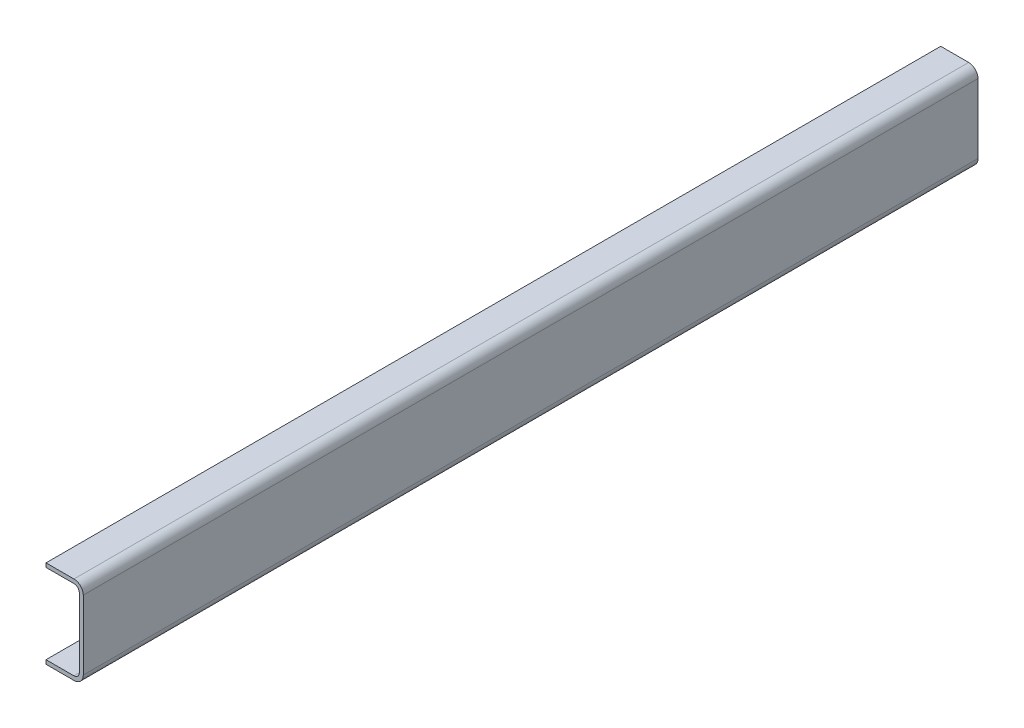
from build123d import *

# Parameters (mm, degrees)
BASE_EXTRUDE_THIN_DEPTH = 2133.6
INSIDE_BEND_RADIUS_R    = 12.7
OUTSIDE_BEND_RADIUS_R   = 22.225


with BuildPart() as part:
    # Sketch1 → Base-Extrude-Thin (new body)
    with BuildSketch(Plane.XY):
        Polygon((-88.9, 0), (0, 0), (0, 209.55), (-88.9, 209.55), (-88.9, 200.025), (-9.525, 200.025), (-9.525, 9.525), (-88.9, 9.525), align=None)
    extrude(amount=-BASE_EXTRUDE_THIN_DEPTH)

    # Inside Bend Radius
    inside_bend_radius_edges = [part.edges().sort_by_distance(p)[0] for p in [
        (-9.525, 200.025, -1066.8),
        (-9.525, 9.525, -1066.8),
    ]]
    fillet(inside_bend_radius_edges, radius=INSIDE_BEND_RADIUS_R)

    # Outside Bend Radius
    outside_bend_radius_edges = [part.edges().sort_by_distance(p)[0] for p in [
        (0, 0, -1066.8),
        (0, 209.55, -1066.8),
    ]]
    fillet(outside_bend_radius_edges, radius=OUTSIDE_BEND_RADIUS_R)


solid = part.part
